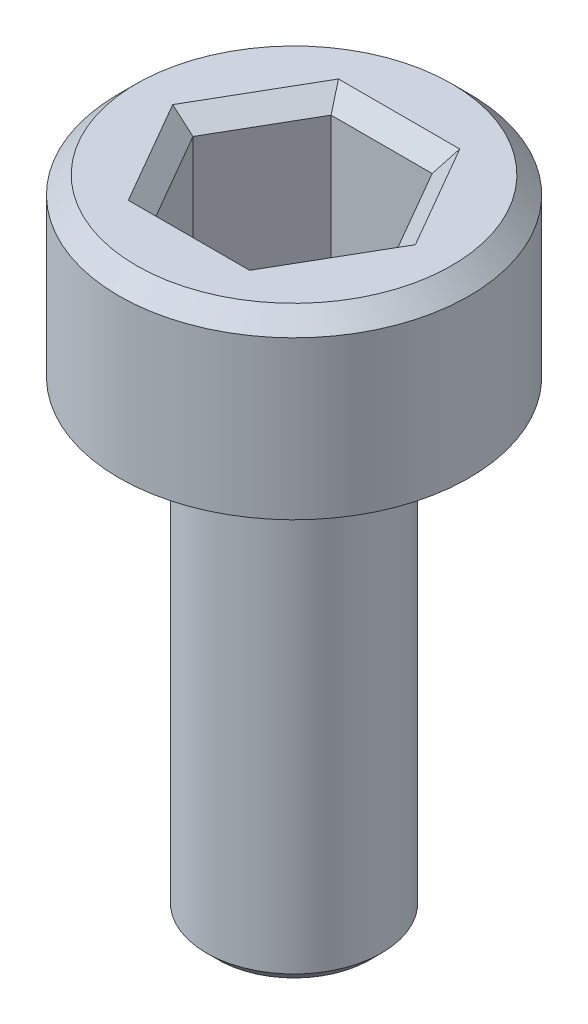
from build123d import *

# Parameters (mm, degrees)
SKETCH1_R           = 3
BOSS_EXTRUDE1_DEPTH = 3
CHAMFER1_SIZE       = 0.3
CUT_EXTRUDE1_DEPTH  = 2.5
CHAMFER2_SIZE       = 0.3
SKETCH3_R           = 1.5
BOSS_EXTRUDE2_DEPTH = 8
CHAMFER3_SIZE       = 0.2


with BuildPart() as part:
    # Sketch1 → Boss-Extrude1 (new body)
    with BuildSketch(Plane(origin=(0, 0, 0), x_dir=(1, 0, 0), z_dir=(0, 1, 0))):
        with Locations(Location((0, 0, 0), (0, 0, 270))):  # turned: the seam where the file's is
            Circle(SKETCH1_R)
    extrude(amount=BOSS_EXTRUDE1_DEPTH)

    # Chamfer1
    chamfer1_edges = [part.edges().sort_by_distance(p)[0] for p in [
        (0, 3, -3),
    ]]
    chamfer(chamfer1_edges, length=CHAMFER1_SIZE)

    # Sketch2 → Cut-Extrude1 (cut)
    with BuildSketch(Plane(origin=(0, 3, 0), x_dir=(1, 0, 0), z_dir=(0, 1, 0))):
        Polygon((1.732050808, 0), (0.866025404, 1.5), (-0.866025404, 1.5), (-1.732050808, 0), (-0.866025404, -1.5), (0.866025404, -1.5), align=None)
    extrude(amount=-CUT_EXTRUDE1_DEPTH, mode=Mode.SUBTRACT)

    # Chamfer2
    chamfer2_edges = [part.edges().sort_by_distance(p)[0] for p in [
        (1.299038106, 3, 0.75),
        (1.299038106, 3, -0.75),
        (0, 3, -1.5),
        (-1.299038106, 3, -0.75),
        (-1.299038106, 3, 0.75),
        (0, 3, 1.5),
    ]]
    chamfer(chamfer2_edges, length=CHAMFER2_SIZE)

    # Sketch3 → Boss-Extrude2 (add)
    with BuildSketch(Plane.XZ):
        with Locations(Location((0, 0, 0), (0, 0, 90))):  # turned: the seam where the file's is
            Circle(SKETCH3_R)
    extrude(amount=BOSS_EXTRUDE2_DEPTH)

    # Chamfer3
    chamfer3_edges = [part.edges().sort_by_distance(p)[0] for p in [
        (0, -8, -1.5),
    ]]
    chamfer(chamfer3_edges, length=CHAMFER3_SIZE)


solid = part.part
